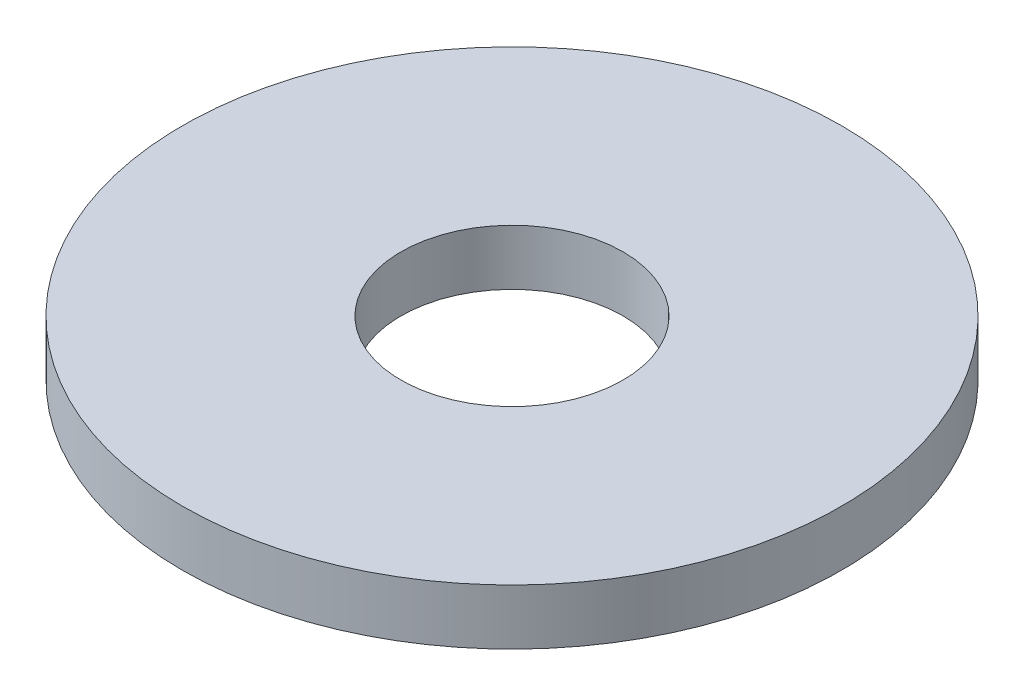
from build123d import *

# Parameters (mm, degrees)
SKIZZE1_W = 11.8
SKIZZE1_H = 3


with BuildPart() as part:
    # Skizze1 → Rotation1 (revolve)
    with BuildSketch(Plane(origin=(0, 0, 0), x_dir=(0, 0, -1), z_dir=(1, 0, 0))):
        with Locations((-11.9, 1.5)):
            Rectangle(SKIZZE1_W, SKIZZE1_H)
    revolve(axis=Axis((0, 0, 0), (0, 1, 0)))


solid = part.part
